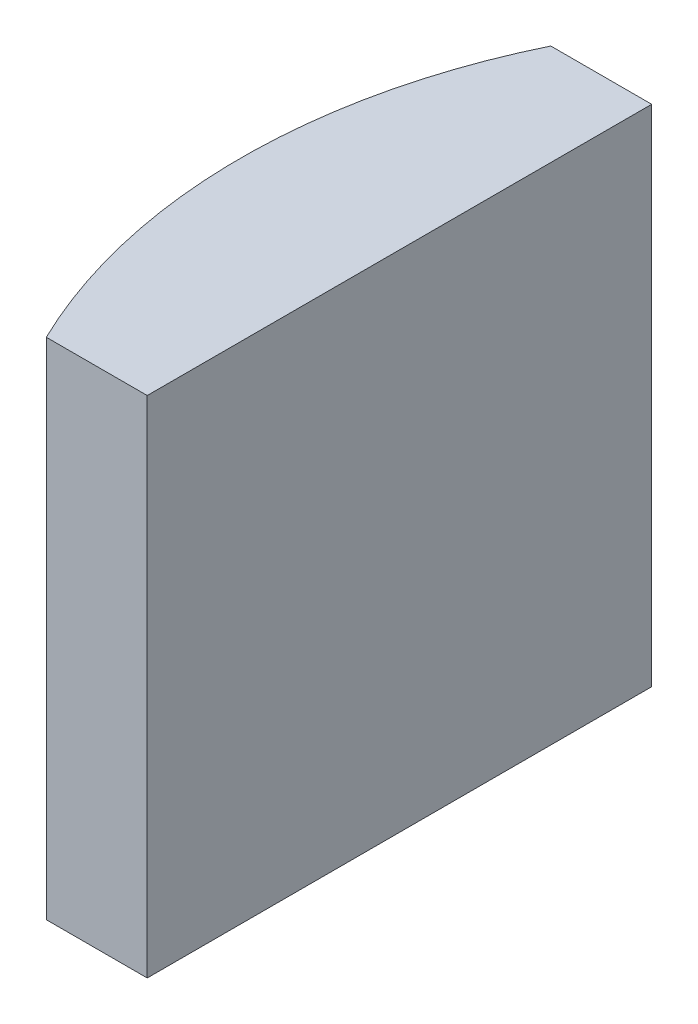
from build123d import *

# Parameters (mm, degrees)
EXTRUDE_1_DEPTH = 10


with BuildPart() as part:
    # 草图1 → 凸台-拉伸1 (new body)
    with BuildSketch(Plane(origin=(0, 0, 0), x_dir=(1, 0, 0), z_dir=(0, 1, 0))):
        with BuildLine():
            Line((-5.945402443, 5), (-3.944795665, 5))
            Line((-3.944795665, 5), (-3.944795665, -5))
            Line((-3.944795665, -5), (-5.945402443, -5))
            ThreePointArc((-5.945402443, -5), (-7.094795665, 0), (-5.945402443, 5))
        make_face()
    extrude(amount=EXTRUDE_1_DEPTH)


solid = part.part
